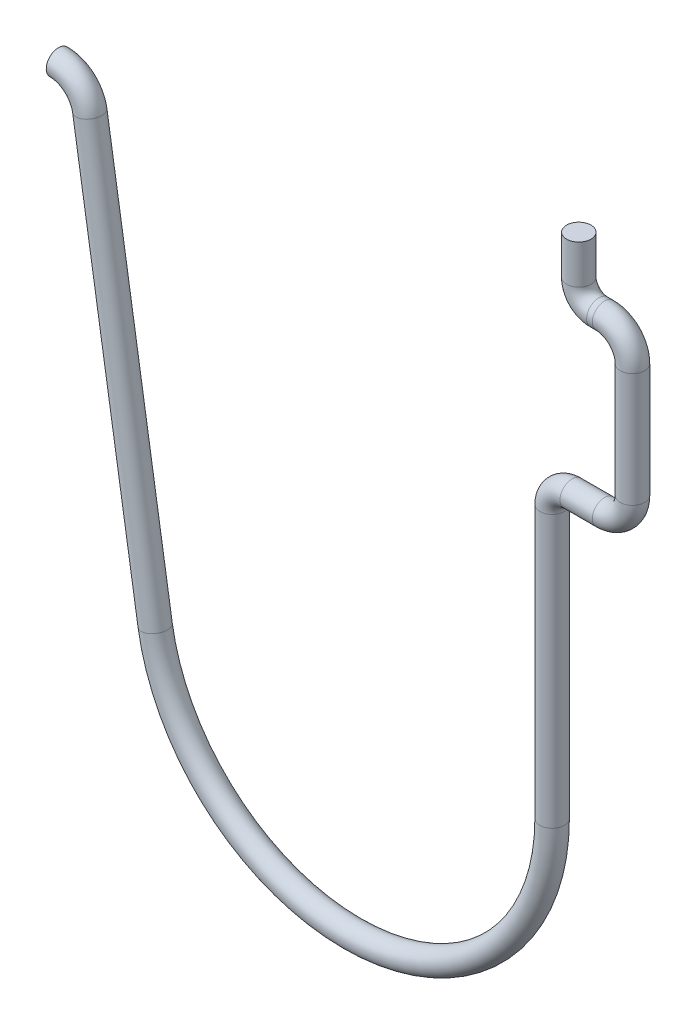
from build123d import *

# Parameters (mm, degrees)
SKETCH2_R = 0.79375


with BuildPart() as part:
    # Sweep1: sweep along a path in Sketch1
    with BuildLine(Plane.XY) as sweep1_path:
        Line((0, 0), (0, -2.54))
        ThreePointArc((0, -2.54), (0.381273748, -3.460476252), (1.30175, -3.84175))
        Line((1.30175, -3.84175), (1.67005, -3.84175))
        ThreePointArc((1.67005, -3.84175), (2.958716753, -4.375533247), (3.4925, -5.6642))
        Line((3.4925, -5.6642), (3.4925, -13.081))
        ThreePointArc((3.4925, -13.081), (2.958716753, -14.369666753), (1.67005, -14.90345))
        Line((1.67005, -14.90345), (-0.431397122, -14.90345))
        ThreePointArc((-0.431397122, -14.90345), (-1.351873374, -15.284723748), (-1.733147122, -16.2052))
        Line((-1.733147122, -16.2052), (-1.733147122, -33.876598998))
        ThreePointArc((-1.733147122, -33.876598998), (-13.699036699, -46.821225414), (-27.542592028, -35.907846364))
        Line((-27.542592028, -35.907846364), (-31.794167919, -9.064452644))
        ThreePointArc((-31.794167919, -9.064452644), (-32.492211322, -7.818006459), (-33.832509732, -7.323544271))
    # Sketch2 → Sweep1 (sweep)
    with BuildSketch(Plane(origin=(0, 0, 0), x_dir=(1, 0, 0), z_dir=(0, 1, 0))):
        Circle(SKETCH2_R)
    sweep(path=sweep1_path.line)


solid = part.part
